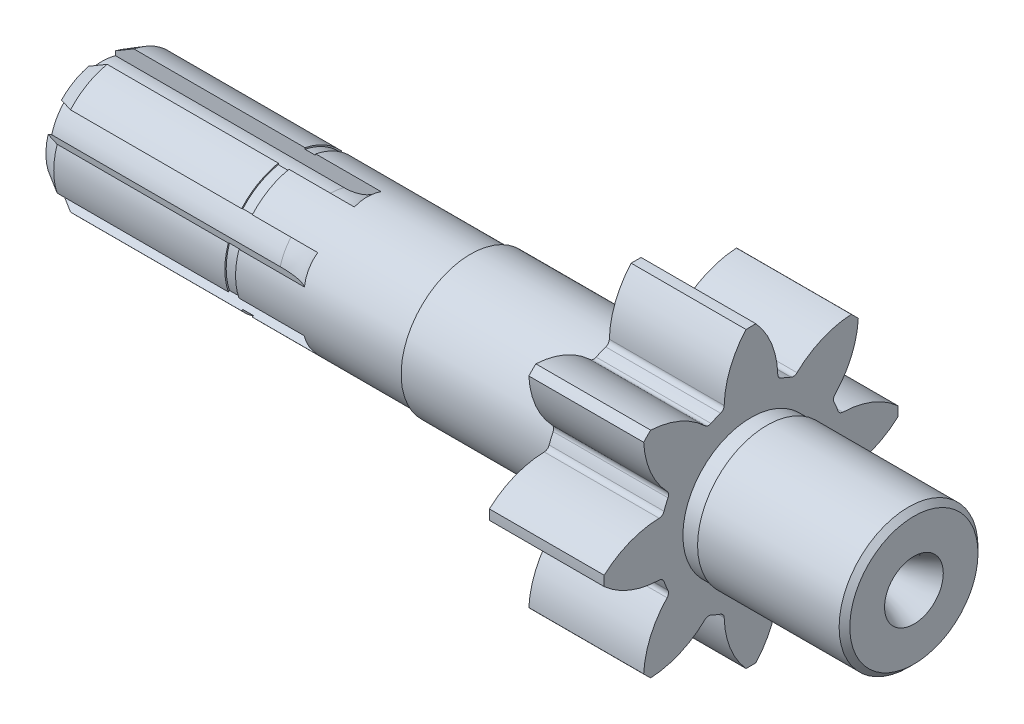
from build123d import *

# Parameters (mm, degrees)
SKETCH_1_R                       = 12.5
EXTRUDE_1_DEPTH                  = 50
SKETCH_3_R                       = 12.5
EXTRUDE_2_DEPTH                  = 19
SKETCH_4_R                       = 13
EXTRUDE_3_DEPTH                  = 31
SKETCH_5_R                       = 17.25
EXTRUDE_4_DEPTH                  = 21.5
SKETCH_6_R                       = 13
EXTRUDE_5_DEPTH                  = 30.5
PATTERN_CIRCULAR_1_COUNT         = 6
SKETCH_15_W                      = 2
SKETCH_15_H                      = 3
CHAMFER_1_SIZE                   = 2
CHAMFER_1_SIZE2                  = 3.464101615
CHAMFER_2_SIZE                   = 1
EXTRUDE_6_DEPTH                  = 21.5
FILLET_1_R                       = 1
PATTERN_CIRCULAR_2_COUNT         = 8
FILLET_1_OF_PATTERN_CIRCULAR_2_R = 1
SKETCH_18_W                      = 3
SKETCH_18_H                      = 3


with BuildPart() as part:
    # Эскиз1 → Бобышка-Вытянуть1 (new body)
    with BuildSketch(Plane(origin=(0, 0, 0), x_dir=(0, 0, -1), z_dir=(1, 0, 0))):
        Circle(SKETCH_1_R)
    extrude(amount=EXTRUDE_1_DEPTH)

    # Эскиз3 → Бобышка-Вытянуть2 (add)
    with BuildSketch(Plane(origin=(50, 0, 0), x_dir=(0, 0, -1), z_dir=(1, 0, 0))):
        Circle(SKETCH_3_R)
    extrude(amount=EXTRUDE_2_DEPTH)

    # Эскиз4 → Бобышка-Вытянуть3 (add)
    with BuildSketch(Plane(origin=(69, 0, 0), x_dir=(0, 0, -1), z_dir=(1, 0, 0))):
        Circle(SKETCH_4_R)
    extrude(amount=EXTRUDE_3_DEPTH)

    # Эскиз5 → Бобышка-Вытянуть4 (add)
    with BuildSketch(Plane(origin=(100, 0, 0), x_dir=(0, 0, -1), z_dir=(1, 0, 0))):
        Circle(SKETCH_5_R)
    extrude(amount=EXTRUDE_4_DEPTH)

    # Эскиз6 → Бобышка-Вытянуть5 (add)
    with BuildSketch(Plane(origin=(121.5, 0, 0), x_dir=(0, 0, -1), z_dir=(1, 0, 0))):
        Circle(SKETCH_6_R)
    extrude(amount=EXTRUDE_5_DEPTH)

    # Вырез-По траектории1: sweep along a path in Эскиз8
    with BuildLine(Plane.XY) as sweep_1_path:
        Line((0, 9.421952542), (42.782897187, 9.421952542))
        ThreePointArc((42.782897187, 9.421952542), (46.70593648, 10.223596019), (50, 12.5))
    # Эскиз7 → Вырез-По траектории1 (sweep, cut)
    with BuildSketch(Plane.ZY):
        with BuildLine():
            Line((2.5, 12.247448714), (2.5, 9.424038412))
            ThreePointArc((2.5, 9.424038412), (0, 9.75), (-2.5, 9.424038412))
            Line((-2.5, 9.424038412), (-2.5, 12.247448714))
            ThreePointArc((-2.5, 12.247448714), (0, 12.5), (2.5, 12.247448714))
        make_face()
    sweep_1 = sweep(path=sweep_1_path.line, mode=Mode.SUBTRACT)

    # Круговой массив1: Вырез-По траектории1 ×6 about axis
    pattern_circular_1_axis = Axis((0, 0, 0), (1, 0, 0))
    for i in range(1, PATTERN_CIRCULAR_1_COUNT):
        add(sweep_1.rotate(pattern_circular_1_axis, i * 360 / PATTERN_CIRCULAR_1_COUNT), mode=Mode.SUBTRACT)

    # Эскиз9 → Отверстие1 (revolve, cut)
    with BuildSketch(Plane(origin=(152, 0, 0), x_dir=(0, 0, -1), z_dir=(0, 1, 0))):
        Polygon((0, 0), (0, 10.5), (0.5, 10.5), (5.5, 0), align=None)
    revolve(axis=Axis((42, 0, 0), (1, 0, 0)), mode=Mode.SUBTRACT)

    # Эскиз14 → Отверстие2 (revolve, cut)
    with BuildSketch(Plane.ZX):
        Polygon((0, 0), (0, 11.30043031), (0.5, 11), (5.25, 0), align=None)
    revolve(axis=Axis((-9.901672523, 0, 0), (1, 0, 0)), mode=Mode.SUBTRACT)

    # Эскиз15 → Вырез-Повернуть1 (revolve, cut)
    with BuildSketch(Plane(origin=(0, 0, 0), x_dir=(1, 0, 0), z_dir=(0, 1, 0))):
        with Locations((36.5, 13.75)):
            Rectangle(SKETCH_15_W, SKETCH_15_H)
    revolve(axis=Axis((0, 0, 0), (1, 0, 0)), mode=Mode.SUBTRACT)

    # Фаска1
    chamfer_1_edges = [part.edges().sort_by_distance(p)[0] for p in [
        (0, 0, -12.5),
        (0, 10.825317547, -6.25),
        (0, 10.825317547, 6.25),
        (0, 0, 12.5),
        (0, -10.825317547, 6.25),
        (0, -10.825317547, -6.25),
    ]]
    chamfer_1_side = [part.faces().sort_by_distance(p)[0] for p in [
        (0, 10.835743563, 2.85),
    ]]
    chamfer(chamfer_1_edges, length=CHAMFER_1_SIZE, length2=CHAMFER_1_SIZE2, reference=chamfer_1_side[0])

    # Фаска2
    chamfer_2_edges = [part.edges().sort_by_distance(p)[0] for p in [
        (152, 0, 13),
    ]]
    chamfer(chamfer_2_edges, length=CHAMFER_2_SIZE)

    # Эскиз16 → Бобышка-Вытянуть6 (add)
    with BuildSketch(Plane.ZY.offset(-100)):
        with BuildLine():
            ThreePointArc((-5.021352821, 16.502985059), (0, 17.25), (5.021352821, 16.502985059))
            ThreePointArc((5.021352821, 16.502985059), (4.016143017, 22.381970452), (0.927672188, 27.484348715))
            ThreePointArc((0.927672188, 27.484348715), (0, 27.5), (-0.927672188, 27.484348715))
            ThreePointArc((-0.927672188, 27.484348715), (-4.016143017, 22.381970452), (-5.021352821, 16.502985059))
        make_face()
    extrude_6 = extrude(amount=-EXTRUDE_6_DEPTH)

    # Скругление1
    fillet_1_edges = [part.edges().sort_by_distance(p)[0] for p in [
        (110.75, 16.502985059, -5.021352821),
        (110.75, 16.502985059, 5.021352821),
    ]]
    fillet(fillet_1_edges, radius=FILLET_1_R)

    # Круговой массив2: Бобышка-Вытянуть6 ×8 about axis
    pattern_circular_2_axis = Axis((0, 0, 0), (1, 0, 0))
    for i in range(1, PATTERN_CIRCULAR_2_COUNT):
        add(extrude_6.rotate(pattern_circular_2_axis, i * 360 / PATTERN_CIRCULAR_2_COUNT))

    # Скругление1 of Круговой массив2
    fillet_1_of_pattern_circular_2_edges = [part.edges().sort_by_distance(p)[0] for p in [
        (110.75, 15.220005275, 8.118740015),
        (110.75, 8.118740015, 15.220005275),
        (110.75, 5.021352821, 16.502985059),
        (110.75, -5.021352821, 16.502985059),
        (110.75, -8.118740015, 15.220005275),
        (110.75, -15.220005275, 8.118740015),
        (110.75, -16.502985059, 5.021352821),
        (110.75, -16.502985059, -5.021352821),
        (110.75, -15.220005275, -8.118740015),
        (110.75, -8.118740015, -15.220005275),
        (110.75, -5.021352821, -16.502985059),
        (110.75, 5.021352821, -16.502985059),
        (110.75, 8.118740015, -15.220005275),
        (110.75, 15.220005275, -8.118740015),
    ]]
    fillet(fillet_1_of_pattern_circular_2_edges, radius=FILLET_1_OF_PATTERN_CIRCULAR_2_R)

    # Эскиз18 → Вырез-Повернуть2 (revolve, cut)
    with BuildSketch(Plane.XY):
        with Locations((98.5, 14.25)):
            Rectangle(SKETCH_18_W, SKETCH_18_H)
        with Locations((123, 14.25)):
            Rectangle(SKETCH_18_W, SKETCH_18_H)
    revolve(axis=Axis((0, 0, 0), (1, 0, 0)), mode=Mode.SUBTRACT)


solid = part.part
